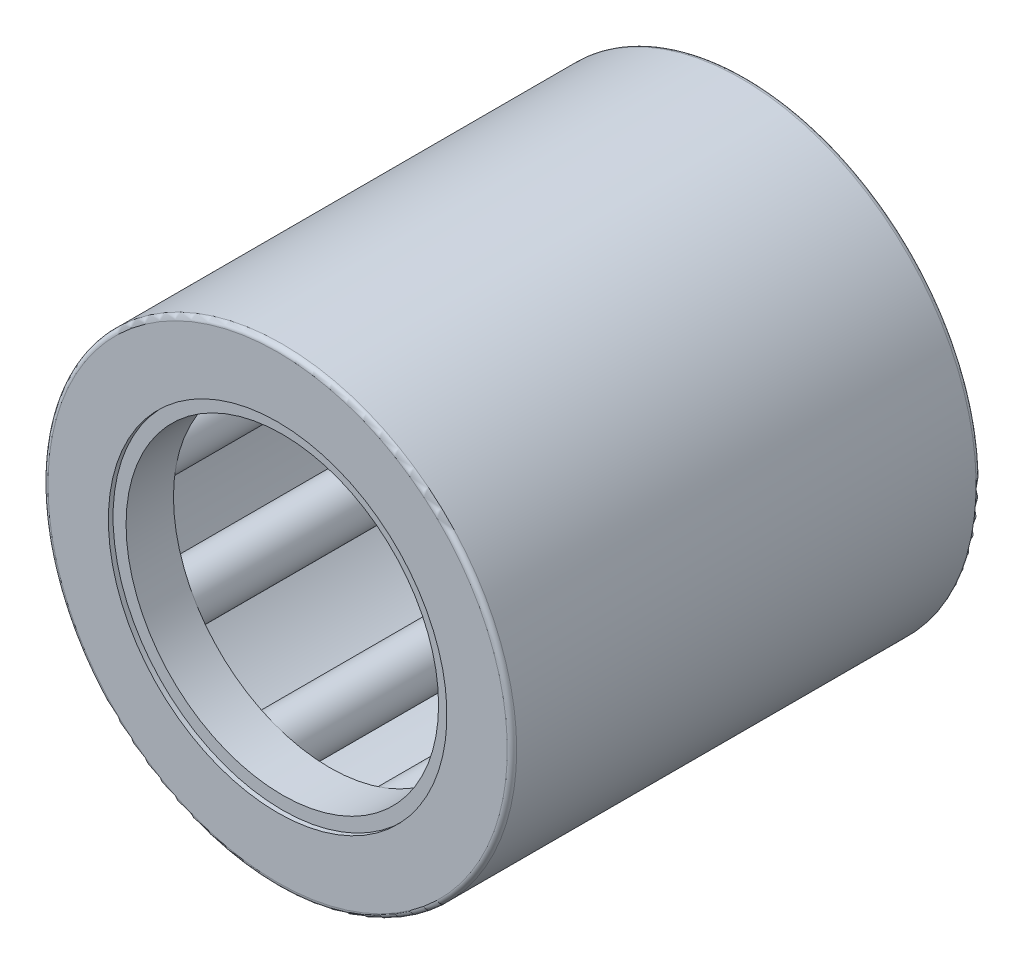
from build123d import *

# Parameters (mm, degrees)
SKETCH2_W         = 9.333333334
SKETCH2_H         = 0.5
SKETCH3_W         = 10.666666666
SKETCH3_H         = 0.166666666
CIRPATTERN1_COUNT = 9
CIRPATTERN1_ANGLE = 320
FILLET1_R         = 0.12
SKETCH4_W         = 1.213333333
SKETCH4_H         = 0.333333333
SKETCH5_W         = 1.213333333
SKETCH5_H         = 0.333333333


with BuildPart() as part:
    # Sketch7 → Revolve1 (revolve)
    with BuildSketch(Plane(origin=(0, 0, 0), x_dir=(0, 0, -1), z_dir=(1, 0, 0))):
        Polygon((-6, 6), (-6, 4.333333333), (-5.333333333, 4.333333333), (-5.333333333, 5.333333333), (5.333333333, 5.333333333), (5.333333333, 4.333333333), (6, 4.333333333), (6, 6), align=None)
    revolve(axis=Axis((0, 0, 6), (0, 0, -1)))

    # Fillet1
    fillet1_edges = [part.edges().sort_by_distance(p)[0] for p in [
        (0, -6, -6),
        (0, -6, 6),
    ]]
    fillet(fillet1_edges, radius=FILLET1_R)


with BuildPart() as body_2:
    # Sketch2 → Revolve2 (revolve)
    with BuildSketch(Plane(origin=(0, 0, 0), x_dir=(0, 0, -1), z_dir=(1, 0, 0))):
        with Locations((0, 5.083333333)):
            Rectangle(SKETCH2_W, SKETCH2_H)
    revolve(axis=Axis((0, 4.666666667, 4.666666667), (0, 0, -1)))


with BuildPart() as body_3:
    # Sketch3 → Revolve3 (revolve)
    with BuildSketch(Plane(origin=(0, 0, 0), x_dir=(0, 0, -1), z_dir=(1, 0, 0))):
        with Locations((0, 4.75)):
            Rectangle(SKETCH3_W, SKETCH3_H)
    revolve(axis=Axis((0, 4.666666667, 5.333333333), (0, 0, -1)))


with BuildPart() as cirpattern1_1:
    # CirPattern1: pattern copy
    add(body_2.part.rotate(Axis((0, 0, 6), (0, 0, -1)), 1 * CIRPATTERN1_ANGLE / (CIRPATTERN1_COUNT - 1)))


with BuildPart() as cirpattern1_2:
    # CirPattern1: pattern copy
    add(body_2.part.rotate(Axis((0, 0, 6), (0, 0, -1)), 2 * CIRPATTERN1_ANGLE / (CIRPATTERN1_COUNT - 1)))


with BuildPart() as cirpattern1_3:
    # CirPattern1: pattern copy
    add(body_2.part.rotate(Axis((0, 0, 6), (0, 0, -1)), 3 * CIRPATTERN1_ANGLE / (CIRPATTERN1_COUNT - 1)))


with BuildPart() as cirpattern1_4:
    # CirPattern1: pattern copy
    add(body_2.part.rotate(Axis((0, 0, 6), (0, 0, -1)), 4 * CIRPATTERN1_ANGLE / (CIRPATTERN1_COUNT - 1)))


with BuildPart() as cirpattern1_5:
    # CirPattern1: pattern copy
    add(body_2.part.rotate(Axis((0, 0, 6), (0, 0, -1)), 5 * CIRPATTERN1_ANGLE / (CIRPATTERN1_COUNT - 1)))


with BuildPart() as cirpattern1_6:
    # CirPattern1: pattern copy
    add(body_2.part.rotate(Axis((0, 0, 6), (0, 0, -1)), 6 * CIRPATTERN1_ANGLE / (CIRPATTERN1_COUNT - 1)))


with BuildPart() as cirpattern1_7:
    # CirPattern1: pattern copy
    add(body_2.part.rotate(Axis((0, 0, 6), (0, 0, -1)), 7 * CIRPATTERN1_ANGLE / (CIRPATTERN1_COUNT - 1)))


with BuildPart() as cirpattern1_8:
    # CirPattern1: pattern copy
    add(body_2.part.rotate(Axis((0, 0, 6), (0, 0, -1)), 8 * CIRPATTERN1_ANGLE / (CIRPATTERN1_COUNT - 1)))


with BuildPart() as cirpattern1_9:
    # CirPattern1: pattern copy
    add(body_3.part.rotate(Axis((0, 0, 6), (0, 0, -1)), 1 * CIRPATTERN1_ANGLE / (CIRPATTERN1_COUNT - 1)))


with BuildPart() as cirpattern1_10:
    # CirPattern1: pattern copy
    add(body_3.part.rotate(Axis((0, 0, 6), (0, 0, -1)), 2 * CIRPATTERN1_ANGLE / (CIRPATTERN1_COUNT - 1)))


with BuildPart() as cirpattern1_11:
    # CirPattern1: pattern copy
    add(body_3.part.rotate(Axis((0, 0, 6), (0, 0, -1)), 3 * CIRPATTERN1_ANGLE / (CIRPATTERN1_COUNT - 1)))


with BuildPart() as cirpattern1_12:
    # CirPattern1: pattern copy
    add(body_3.part.rotate(Axis((0, 0, 6), (0, 0, -1)), 4 * CIRPATTERN1_ANGLE / (CIRPATTERN1_COUNT - 1)))


with BuildPart() as cirpattern1_13:
    # CirPattern1: pattern copy
    add(body_3.part.rotate(Axis((0, 0, 6), (0, 0, -1)), 5 * CIRPATTERN1_ANGLE / (CIRPATTERN1_COUNT - 1)))


with BuildPart() as cirpattern1_14:
    # CirPattern1: pattern copy
    add(body_3.part.rotate(Axis((0, 0, 6), (0, 0, -1)), 6 * CIRPATTERN1_ANGLE / (CIRPATTERN1_COUNT - 1)))


with BuildPart() as cirpattern1_15:
    # CirPattern1: pattern copy
    add(body_3.part.rotate(Axis((0, 0, 6), (0, 0, -1)), 7 * CIRPATTERN1_ANGLE / (CIRPATTERN1_COUNT - 1)))


with BuildPart() as cirpattern1_16:
    # CirPattern1: pattern copy
    add(body_3.part.rotate(Axis((0, 0, 6), (0, 0, -1)), 8 * CIRPATTERN1_ANGLE / (CIRPATTERN1_COUNT - 1)))


with BuildPart() as body_20:
    # Sketch4 → Revolve4 (revolve)
    with BuildSketch(Plane(origin=(0, 0, 0), x_dir=(0, 0, -1), z_dir=(1, 0, 0))):
        with Locations((5.273333334, 4.166666667)):
            Rectangle(SKETCH4_W, SKETCH4_H)
    revolve(axis=Axis((0, 0, 6), (0, 0, -1)))


with BuildPart() as body_21:
    # Sketch5 → Revolve5 (revolve)
    with BuildSketch(Plane(origin=(0, 0, 0), x_dir=(0, 0, -1), z_dir=(1, 0, 0))):
        with Locations((-5.273333334, 4.166666667)):
            Rectangle(SKETCH5_W, SKETCH5_H)
    revolve(axis=Axis((0, 0, 6), (0, 0, -1)))


solid = Compound([part.part, body_2.part, body_3.part, cirpattern1_1.part, cirpattern1_2.part, cirpattern1_3.part, cirpattern1_4.part, cirpattern1_5.part, cirpattern1_6.part, cirpattern1_7.part, cirpattern1_8.part, cirpattern1_9.part, cirpattern1_10.part, cirpattern1_11.part, cirpattern1_12.part, cirpattern1_13.part, cirpattern1_14.part, cirpattern1_15.part, cirpattern1_16.part, body_20.part, body_21.part])
